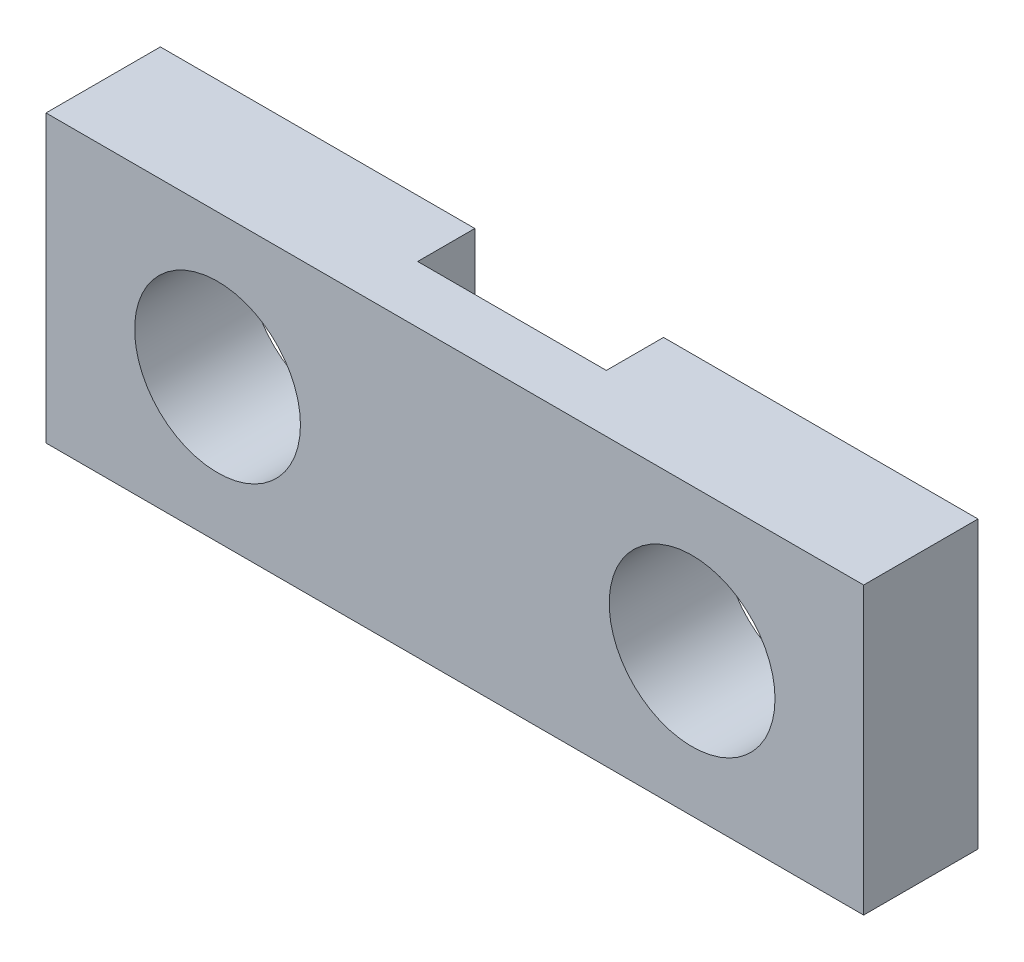
from build123d import *

# Parameters (mm, degrees)
SKETCH2_W              = 5
SKETCH2_H              = 14.3
BOSS_EXTRUDE1_DEPTH    = 2
SKETCH2_4_W            = 5
SKETCH2_4_H            = 3.3
CUT_EXTRUDE1_DEPTH     = 1
M2_5_CLEARANCE_HOLE1_D = 2.9


with BuildPart() as part:
    # Sketch2 → Boss-Extrude1 (new body)
    with BuildSketch(Plane(origin=(0, 0, 0), x_dir=(0, 1, 0), z_dir=(0, 0, 1))):
        Rectangle(SKETCH2_W, SKETCH2_H)
    extrude(amount=BOSS_EXTRUDE1_DEPTH)

    # Sketch2_4 → Cut-Extrude1 (cut)
    with BuildSketch(Plane(origin=(0, 0, 0), x_dir=(0, 1, 0), z_dir=(0, 0, 1))):
        Rectangle(SKETCH2_4_W, SKETCH2_4_H)
    extrude(amount=CUT_EXTRUDE1_DEPTH, mode=Mode.SUBTRACT)

    # M2.5 Clearance Hole1 (through all)
    with Locations(Plane.XY.offset(2)):
        with Locations((-4.15, 0), (4.15, 0)):
            Hole(M2_5_CLEARANCE_HOLE1_D / 2)


solid = part.part
